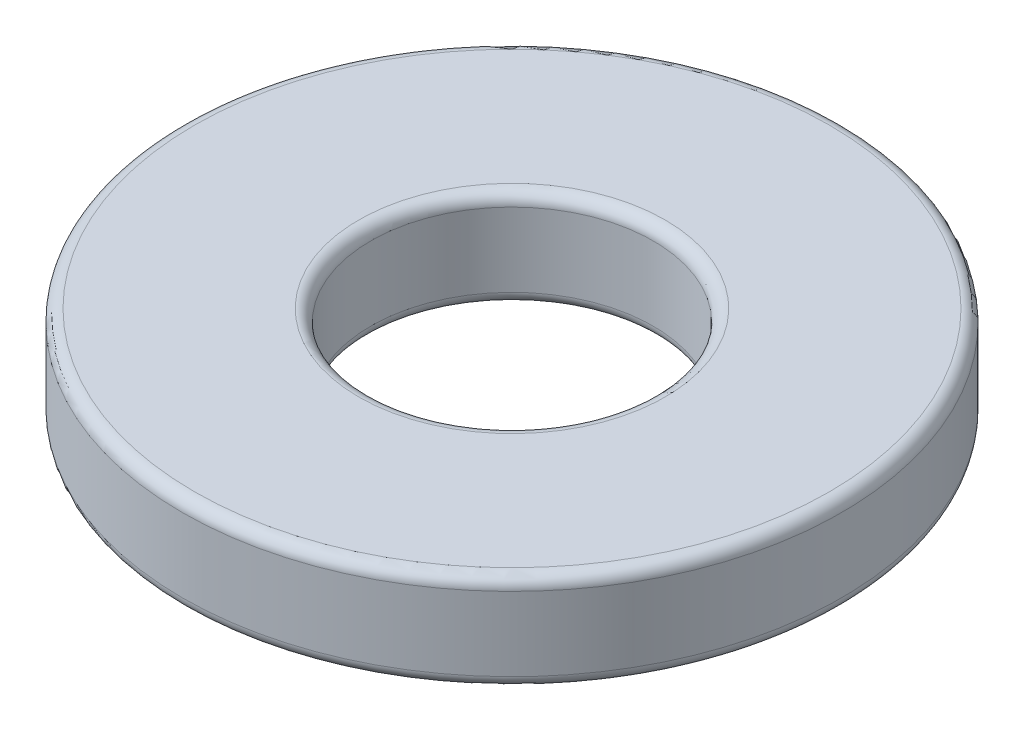
from build123d import *

# Parameters (mm, degrees)
SKETCH1_R           = 5.55625
BOSS_EXTRUDE1_DEPTH = 1.651
SKETCH5_R           = 2.38125
CUT_EXTRUDE1_DEPTH  = 2.651
FILLET1_R           = 0.2032


with BuildPart() as part:
    # Sketch1 → Boss-Extrude1 (new body)
    with BuildSketch(Plane(origin=(0, 0, 0), x_dir=(1, 0, 0), z_dir=(0, 1, 0))):
        Circle(SKETCH1_R)
    extrude(amount=BOSS_EXTRUDE1_DEPTH)

    # Sketch5 → Cut-Extrude1 (cut, through all)
    with BuildSketch(Plane(origin=(0, 1.651, 0), x_dir=(-1, 0, 0), z_dir=(0, 1, 0))):
        Circle(SKETCH5_R)
    extrude(amount=-CUT_EXTRUDE1_DEPTH, mode=Mode.SUBTRACT)

    # Fillet1
    fillet1_edges = [part.edges().sort_by_distance(p)[0] for p in [
        (-5.55625, 0, 0),
        (-5.55625, 1.651, 0),
        (2.38125, 0, 0),
        (2.38125, 1.651, 0),
    ]]
    fillet(fillet1_edges, radius=FILLET1_R)


solid = part.part
